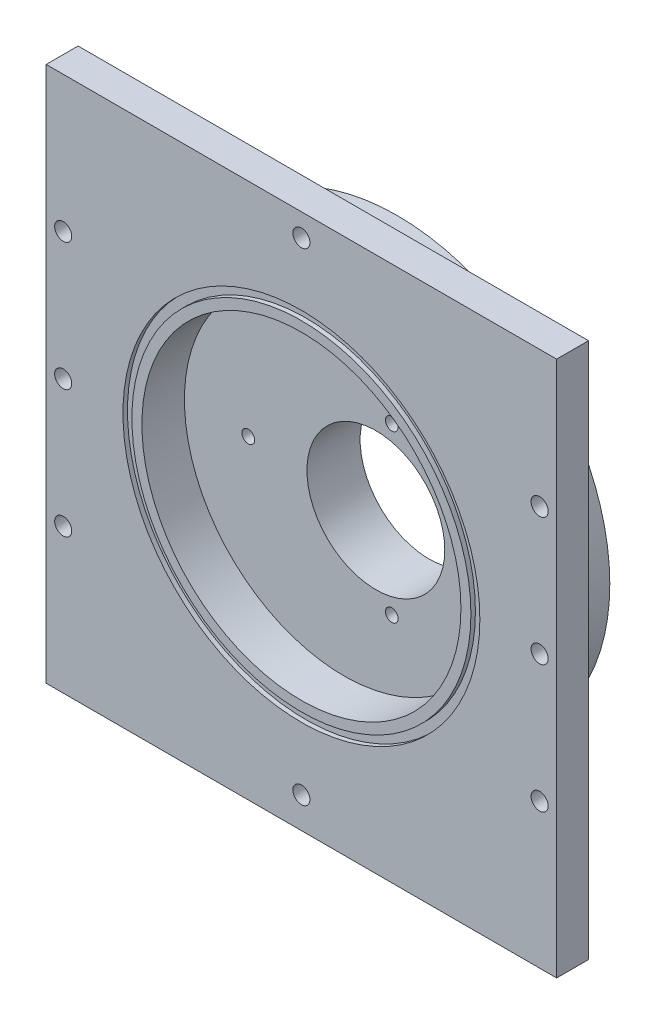
from build123d import *

# Parameters (mm, degrees)
SKETCH1_W                                       = 152.4
SKETCH1_H                                       = 157.48
BOSS_EXTRUDE1_DEPTH                             = 9.525
SKETCH16_W                                      = 152.4
SKETCH16_H                                      = 9.525
BOSS_EXTRUDE2_DEPTH                             = 2.54
M100_CLEARANCE_HOLE1_D                          = 106.553
M100_CLEARANCE_HOLE1_DEPTH                      = 1.3462
SKETCH4_W                                       = 63.5
SKETCH4_H                                       = 19.05
SKETCH5_W                                       = 50.6095
SKETCH5_H                                       = 1.3462
CBORE_FOR_10_SOCKET_HEAD_CAP_SCREW1_D           = 5.1054
CBORE_FOR_10_SOCKET_HEAD_CAP_SCREW1_CBORE_D     = 9.525
CBORE_FOR_10_SOCKET_HEAD_CAP_SCREW1_CBORE_DEPTH = 4.826
F_10_24_TAPPED_HOLE1_D                          = 3.7973
F_10_24_TAPPED_HOLE1_DEPTH                      = 8.89
F_10_24_TAPPED_HOLE1_TIP                        = 1.140824014
M90_CLEARANCE_HOLE1_D                           = 95.25
M90_CLEARANCE_HOLE1_DEPTH                       = 12.7
M36_CLEARANCE_HOLE1_D                           = 41.148
M36_CLEARANCE_HOLE1_DEPTH                       = 15.875
F_10_24_TAPPED_HOLE2_D                          = 3.7973
F_10_24_TAPPED_HOLE2_DEPTH                      = 7.74954
F_10_24_TAPPED_HOLE2_TIP                        = 1.140824014


with BuildPart() as part:
    # Sketch1 → Boss-Extrude1 (new body)
    with BuildSketch(Plane(origin=(0, 0, 0), x_dir=(-1, 0, 0), z_dir=(0, 0, -1))):
        with Locations((0, -2.54)):
            Rectangle(SKETCH1_W, SKETCH1_H)
    extrude(amount=-BOSS_EXTRUDE1_DEPTH)

    # Sketch16 → Boss-Extrude2 (add)
    with BuildSketch(Plane(origin=(0, 76.2, 0), x_dir=(1, 0, 0), z_dir=(0, 1, 0))):
        with Locations((0, -4.7625)):
            Rectangle(SKETCH16_W, SKETCH16_H)
    extrude(amount=BOSS_EXTRUDE2_DEPTH)

    # M100 Clearance Hole1
    with Locations(Plane.XY.offset(9.525)):
        with Locations((0, 0)):
            Hole(M100_CLEARANCE_HOLE1_D / 2, depth=M100_CLEARANCE_HOLE1_DEPTH)

    # Sketch4 → Revolve1 (revolve)
    with BuildSketch(Plane(origin=(0, 0, 0), x_dir=(1, 0, 0), z_dir=(0, 1, 0))):
        with Locations((31.75, 9.525)):
            Rectangle(SKETCH4_W, SKETCH4_H)
    revolve(axis=Axis((0, 0, -19.05), (0, 0, 1)))

    # Sketch5 → Revolve2 (revolve)
    with BuildSketch(Plane(origin=(0, 0, 0), x_dir=(1, 0, 0), z_dir=(0, 1, 0))):
        with Locations((25.30475, -8.8519)):
            Rectangle(SKETCH5_W, SKETCH5_H)
    revolve(axis=Axis((0, 0, 8.1788), (0, 0, 1)))

    # CBORE for #10 Socket Head Cap Screw1 (through all)
    with Locations(Plane(origin=(0, 0, 0), x_dir=(-1, 0, 0), z_dir=(0, 0, -1))):
        with Locations((71.12, 38.1), (71.12, -38.1), (-71.12, 38.1), (-71.12, -38.1), (0, 72.009), (0, -72.009), (71.12, 0), (-71.12, 0)):
            CounterBoreHole(CBORE_FOR_10_SOCKET_HEAD_CAP_SCREW1_D / 2, CBORE_FOR_10_SOCKET_HEAD_CAP_SCREW1_CBORE_D / 2, CBORE_FOR_10_SOCKET_HEAD_CAP_SCREW1_CBORE_DEPTH)

    # #10-24 Tapped Hole1
    with Locations(Plane(origin=(0, 0, -19.05), x_dir=(-1, 0, 0), z_dir=(0, 0, -1))):
        with Locations((17.311395212, 15.494), (17.311395212, -15.494), (-9.525, -30.988), (-36.361395212, -15.494), (-36.361395212, 15.494), (-9.525, 30.988)):
            Hole(F_10_24_TAPPED_HOLE1_D / 2, depth=F_10_24_TAPPED_HOLE1_DEPTH)
            with Locations((0, 0, -(F_10_24_TAPPED_HOLE1_DEPTH + F_10_24_TAPPED_HOLE1_TIP / 2))):  # 118° drill point
                Cone(0, F_10_24_TAPPED_HOLE1_D / 2, F_10_24_TAPPED_HOLE1_TIP, mode=Mode.SUBTRACT)

    # M90 Clearance Hole1
    with Locations(Plane.XY.offset(9.525)):
        with Locations((0, 0)):
            Hole(M90_CLEARANCE_HOLE1_D / 2, depth=M90_CLEARANCE_HOLE1_DEPTH)

    # M36 Clearance Hole1
    with Locations(Plane.XY.offset(-3.175)):
        with Locations((9.525, 0)):
            Hole(M36_CLEARANCE_HOLE1_D / 2, depth=M36_CLEARANCE_HOLE1_DEPTH)

    # #10-24 Tapped Hole2
    with Locations(Plane.XY.offset(-3.175)):
        with Locations((14.2875, -24.746675913), (-28.575, 0), (14.2875, 24.746675913)):
            Hole(F_10_24_TAPPED_HOLE2_D / 2, depth=F_10_24_TAPPED_HOLE2_DEPTH)
            with Locations((0, 0, -(F_10_24_TAPPED_HOLE2_DEPTH + F_10_24_TAPPED_HOLE2_TIP / 2))):  # 118° drill point
                Cone(0, F_10_24_TAPPED_HOLE2_D / 2, F_10_24_TAPPED_HOLE2_TIP, mode=Mode.SUBTRACT)


solid = part.part
